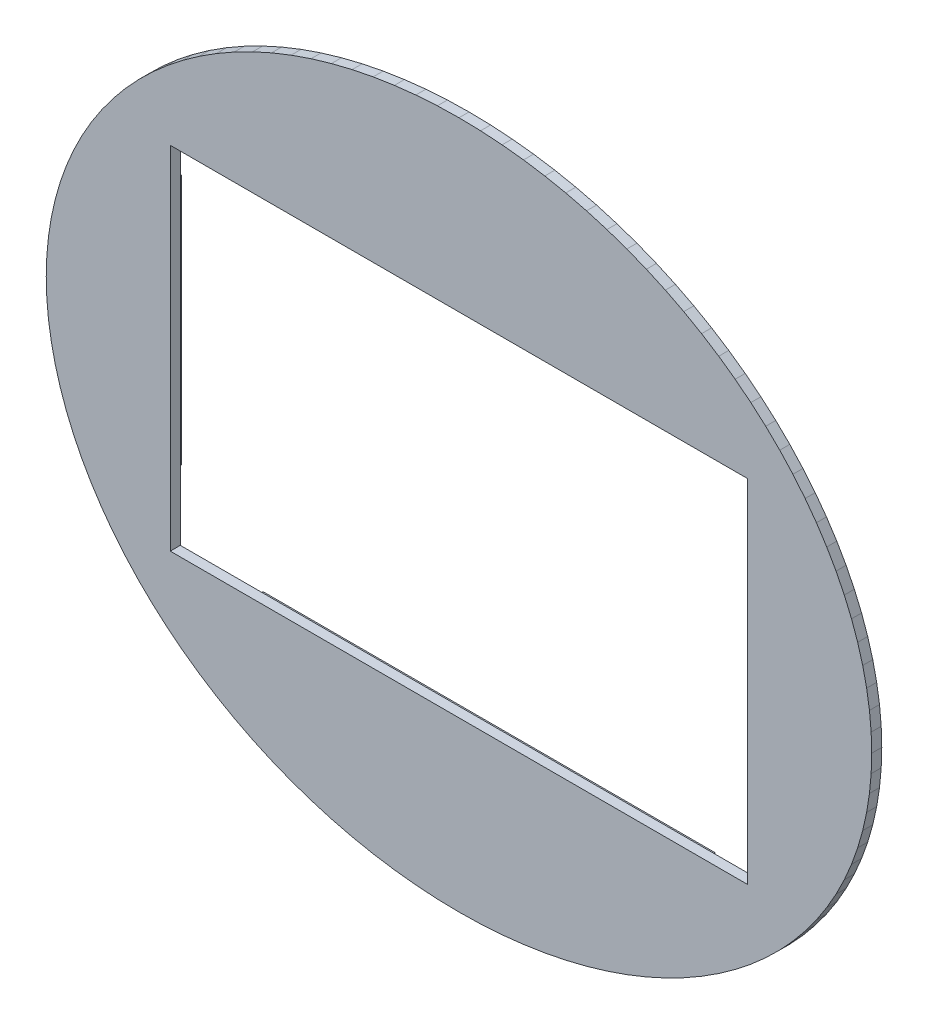
from build123d import *

# Parameters (mm, degrees)
BOSS_EXTRUDE1_DEPTH             = 2000
SKETCH2_W                       = 115000
SKETCH2_H                       = 70000
CUT_EXTRUDE1_DEPTH              = 2001
SKETCH3_W                       = 2250
SKETCH3_H                       = 50000
BOSS_EXTRUDE2_DEPTH             = 4000
SKETCH4_W                       = 90000
SKETCH4_H                       = 2250
BOSS_EXTRUDE3_DEPTH             = 4000
SKETCH5_W                       = 90000
SKETCH5_H                       = 2250
BOSS_EXTRUDE4_DEPTH             = 4000
SKETCH6_W                       = 2250
SKETCH6_H                       = 50000
BOSS_EXTRUDE5_DEPTH             = 4000
SCALE4_SCALE                    = 0.001
SKETCH17_W                      = 4
SKETCH17_H                      = 50
BOSS_EXTRUDE7_DEPTH             = 4
F_40_0_098_DIAMETER_HOLE1_D     = 2.50000008
F_40_0_098_DIAMETER_HOLE1_DEPTH = 3
F_40_0_098_DIAMETER_HOLE1_TIP   = 0.751075798
SKETCH21_W                      = 90
SKETCH21_H                      = 4
BOSS_EXTRUDE8_DEPTH             = 4
SKETCH22_W                      = 4
SKETCH22_H                      = 50
BOSS_EXTRUDE9_DEPTH             = 4
SKETCH23_W                      = 90
SKETCH23_H                      = 4
BOSS_EXTRUDE10_DEPTH            = 4
M2_5_CLEARANCE_HOLE3_D          = 2.9
M2_5_CLEARANCE_HOLE3_DEPTH      = 3
M2_5_CLEARANCE_HOLE3_TIP        = 0.871247898
M2_5_CLEARANCE_HOLE4_D          = 2.9
M2_5_CLEARANCE_HOLE4_DEPTH      = 3
M2_5_CLEARANCE_HOLE4_TIP        = 0.871247898
M2_5_CLEARANCE_HOLE5_D          = 2.9
M2_5_CLEARANCE_HOLE5_DEPTH      = 3
M2_5_CLEARANCE_HOLE5_TIP        = 0.871247898


with BuildPart() as part:
    # Sketch1 → Boss-Extrude1 (new body)
    with BuildSketch(Plane(origin=(0, 0, 66500), x_dir=(-1, 0, 0), z_dir=(0, 0, -1))):
        Polygon((41099.998474121, 59322.700500488), (37318.000793457, 61033.9012146), (33433.799743652, 62577.899932861), (29457.799911499, 63950.298309326), (25401.19934082, 65147.399902344), (21274.900436401, 66165.901184082), (17090.299606323, 67003.09753418), (12858.90007019, 67656.600952148), (8592.240333557, 68124.702453613), (4302.020072937, 68406.097412109), (0, 68500), (-4302.020072937, 68406.097412109), (-8592.240333557, 68124.702453613), (-12858.90007019, 67656.600952148), (-17090.299606323, 67003.09753418), (-21274.900436401, 66165.901184082), (-25401.19934082, 65147.399902344), (-29457.799911499, 63950.298309326), (-33433.799743652, 62577.899932861), (-37318.000793457, 61033.9012146), (-41099.998474121, 59322.700500488), (-44769.298553467, 57448.89831543), (-48315.898895264, 55417.701721191), (-51730.098724365, 53234.50088501), (-55002.498626709, 50905.39932251), (-58124.198913574, 48436.798095703), (-61086.498260498, 45835.399627686), (-63881.401062012, 43108.3984375), (-66501.197814941, 40263.301849365), (-68938.697814941, 37307.800292969), (-71187.301635742, 34250), (-73240.699768066, 31098.300933838), (-75093.399047852, 27861.499786377), (-76740.303039551, 24548.2006073), (-78176.803588867, 21167.699813843), (-79399.101257324, 17729.099273682), (-80403.701782227, 14241.99962616), (-81188.003540039, 10715.800285339), (-81749.702453613, 7160.200119019), (-82087.303161621, 3585.010051727), (-82199.996948242, 0), (-82087.303161621, -3585.010051727), (-81749.702453613, -7160.200119019), (-81188.003540039, -10715.800285339), (-80403.701782227, -14241.99962616), (-79399.101257324, -17729.099273682), (-78176.803588867, -21167.699813843), (-76740.303039551, -24548.2006073), (-75093.399047852, -27861.499786377), (-73240.699768066, -31098.300933838), (-71187.301635742, -34250), (-68938.697814941, -37307.800292969), (-66501.197814941, -40263.301849365), (-63881.401062012, -43108.3984375), (-61086.498260498, -45835.399627686), (-58124.198913574, -48436.798095703), (-55002.498626709, -50905.39932251), (-51730.098724365, -53234.50088501), (-48315.898895264, -55417.701721191), (-44769.298553467, -57448.89831543), (-41099.998474121, -59322.700500488), (-37318.000793457, -61033.9012146), (-33433.799743652, -62577.899932861), (-29457.799911499, -63950.298309326), (-25401.19934082, -65147.399902344), (-21274.900436401, -66165.901184082), (-17090.299606323, -67003.09753418), (-12858.90007019, -67656.600952148), (-8592.240333557, -68124.702453613), (-4302.020072937, -68406.097412109), (0, -68500), (4302.020072937, -68406.097412109), (8592.240333557, -68124.702453613), (12858.90007019, -67656.600952148), (17090.299606323, -67003.09753418), (21274.900436401, -66165.901184082), (25401.19934082, -65147.399902344), (29457.799911499, -63950.298309326), (33433.799743652, -62577.899932861), (37318.000793457, -61033.9012146), (41099.998474121, -59322.700500488), (44769.298553467, -57448.89831543), (48315.898895264, -55417.701721191), (51730.098724365, -53234.50088501), (55002.498626709, -50905.39932251), (58124.198913574, -48436.798095703), (61086.498260498, -45835.399627686), (63881.401062012, -43108.3984375), (66501.197814941, -40263.301849365), (68938.697814941, -37307.800292969), (71187.301635742, -34250), (73240.699768066, -31098.300933838), (75093.399047852, -27861.499786377), (76740.303039551, -24548.2006073), (78176.803588867, -21167.699813843), (79399.101257324, -17729.099273682), (80403.701782227, -14241.99962616), (81188.003540039, -10715.800285339), (81749.702453613, -7160.200119019), (82087.303161621, -3585.010051727), (82199.996948242, 0), (82087.303161621, 3585.010051727), (81749.702453613, 7160.200119019), (81188.003540039, 10715.800285339), (80403.701782227, 14241.99962616), (79399.101257324, 17729.099273682), (78176.803588867, 21167.699813843), (76740.303039551, 24548.2006073), (75093.399047852, 27861.499786377), (73240.699768066, 31098.300933838), (71187.301635742, 34250), (68938.697814941, 37307.800292969), (66501.197814941, 40263.301849365), (63881.401062012, 43108.3984375), (61086.498260498, 45835.399627686), (58124.198913574, 48436.798095703), (55002.498626709, 50905.39932251), (51730.098724365, 53234.50088501), (48315.898895264, 55417.701721191), (44769.298553467, 57448.89831543), align=None)
    extrude(amount=-BOSS_EXTRUDE1_DEPTH)

    # Sketch2 → Cut-Extrude1 (cut, through all)
    with BuildSketch(Plane.XY.offset(68500)):
        Rectangle(SKETCH2_W, SKETCH2_H)
    extrude(amount=-CUT_EXTRUDE1_DEPTH, mode=Mode.SUBTRACT)

    # Sketch3 → Boss-Extrude2 (add)
    with BuildSketch(Plane(origin=(0, 0, 66500), x_dir=(-1, 0, 0), z_dir=(0, 0, -1))):
        with Locations((62375, 0)):
            Rectangle(SKETCH3_W, SKETCH3_H)
    extrude(amount=BOSS_EXTRUDE2_DEPTH)

    # Sketch4 → Boss-Extrude3 (add)
    with BuildSketch(Plane(origin=(0, 0, 66500), x_dir=(-1, 0, 0), z_dir=(0, 0, -1))):
        with Locations((0, 39875)):
            Rectangle(SKETCH4_W, SKETCH4_H)
    extrude(amount=BOSS_EXTRUDE3_DEPTH)

    # Sketch5 → Boss-Extrude4 (add)
    with BuildSketch(Plane(origin=(0, 0, 66500), x_dir=(-1, 0, 0), z_dir=(0, 0, -1))):
        with Locations((0, -39875)):
            Rectangle(SKETCH5_W, SKETCH5_H)
    extrude(amount=BOSS_EXTRUDE4_DEPTH)

    # Sketch6 → Boss-Extrude5 (add)
    with BuildSketch(Plane(origin=(0, 0, 66500), x_dir=(-1, 0, 0), z_dir=(0, 0, -1))):
        with Locations((-62375, 0)):
            Rectangle(SKETCH6_W, SKETCH6_H)
    extrude(amount=BOSS_EXTRUDE5_DEPTH)


with BuildPart() as part_1:
    # Scale4: scaled about (0, 0, 67152.933263132)
    add(part.part.scale(SCALE4_SCALE).moved(Location((0, 0, 67085.780329869))))

    # Sketch17 → Boss-Extrude7 (add)
    with BuildSketch(Plane(origin=(0, 0, 67152.280329869), x_dir=(-1, 0, 0), z_dir=(0, 0, -1))):
        with Locations((-63.25, 0)):
            Rectangle(SKETCH17_W, SKETCH17_H)
    extrude(amount=BOSS_EXTRUDE7_DEPTH)

    # #40 (0.098) Diameter Hole1
    with Locations(Plane(origin=(0, 0, 67148.280329869), x_dir=(-1, 0, 0), z_dir=(0, 0, -1))):
        with Locations((-63.25, 0)):
            Hole(F_40_0_098_DIAMETER_HOLE1_D / 2, depth=F_40_0_098_DIAMETER_HOLE1_DEPTH)
            with Locations((0, 0, -(F_40_0_098_DIAMETER_HOLE1_DEPTH + F_40_0_098_DIAMETER_HOLE1_TIP / 2))):  # 118° drill point
                Cone(0, F_40_0_098_DIAMETER_HOLE1_D / 2, F_40_0_098_DIAMETER_HOLE1_TIP, mode=Mode.SUBTRACT)

    # Sketch21 → Boss-Extrude8 (add)
    with BuildSketch(Plane(origin=(0, 0, 67152.280329869), x_dir=(-1, 0, 0), z_dir=(0, 0, -1))):
        with Locations((0, 40.75)):
            Rectangle(SKETCH21_W, SKETCH21_H)
    extrude(amount=BOSS_EXTRUDE8_DEPTH)

    # Sketch22 → Boss-Extrude9 (add)
    with BuildSketch(Plane(origin=(0, 0, 67152.280329869), x_dir=(-1, 0, 0), z_dir=(0, 0, -1))):
        with Locations((63.25, 0)):
            Rectangle(SKETCH22_W, SKETCH22_H)
    extrude(amount=BOSS_EXTRUDE9_DEPTH)

    # Sketch23 → Boss-Extrude10 (add)
    with BuildSketch(Plane(origin=(0, 0, 67152.280329869), x_dir=(-1, 0, 0), z_dir=(0, 0, -1))):
        with Locations((0, -40.75)):
            Rectangle(SKETCH23_W, SKETCH23_H)
    extrude(amount=BOSS_EXTRUDE10_DEPTH)

    # M2.5 Clearance Hole3
    with Locations(Plane(origin=(0, 0, 67148.280329869), x_dir=(-1, 0, 0), z_dir=(0, 0, -1))):
        with Locations((0, -40.75)):
            Hole(M2_5_CLEARANCE_HOLE3_D / 2, depth=M2_5_CLEARANCE_HOLE3_DEPTH)
            with Locations((0, 0, -(M2_5_CLEARANCE_HOLE3_DEPTH + M2_5_CLEARANCE_HOLE3_TIP / 2))):  # 118° drill point
                Cone(0, M2_5_CLEARANCE_HOLE3_D / 2, M2_5_CLEARANCE_HOLE3_TIP, mode=Mode.SUBTRACT)

    # M2.5 Clearance Hole4
    with Locations(Plane(origin=(0, 0, 67148.280329869), x_dir=(-1, 0, 0), z_dir=(0, 0, -1))):
        with Locations((0, 40.75)):
            Hole(M2_5_CLEARANCE_HOLE4_D / 2, depth=M2_5_CLEARANCE_HOLE4_DEPTH)
            with Locations((0, 0, -(M2_5_CLEARANCE_HOLE4_DEPTH + M2_5_CLEARANCE_HOLE4_TIP / 2))):  # 118° drill point
                Cone(0, M2_5_CLEARANCE_HOLE4_D / 2, M2_5_CLEARANCE_HOLE4_TIP, mode=Mode.SUBTRACT)

    # M2.5 Clearance Hole5
    with Locations(Plane(origin=(0, 0, 67148.280329869), x_dir=(-1, 0, 0), z_dir=(0, 0, -1))):
        with Locations((63.25, 0)):
            Hole(M2_5_CLEARANCE_HOLE5_D / 2, depth=M2_5_CLEARANCE_HOLE5_DEPTH)
            with Locations((0, 0, -(M2_5_CLEARANCE_HOLE5_DEPTH + M2_5_CLEARANCE_HOLE5_TIP / 2))):  # 118° drill point
                Cone(0, M2_5_CLEARANCE_HOLE5_D / 2, M2_5_CLEARANCE_HOLE5_TIP, mode=Mode.SUBTRACT)


solid = part_1.part
